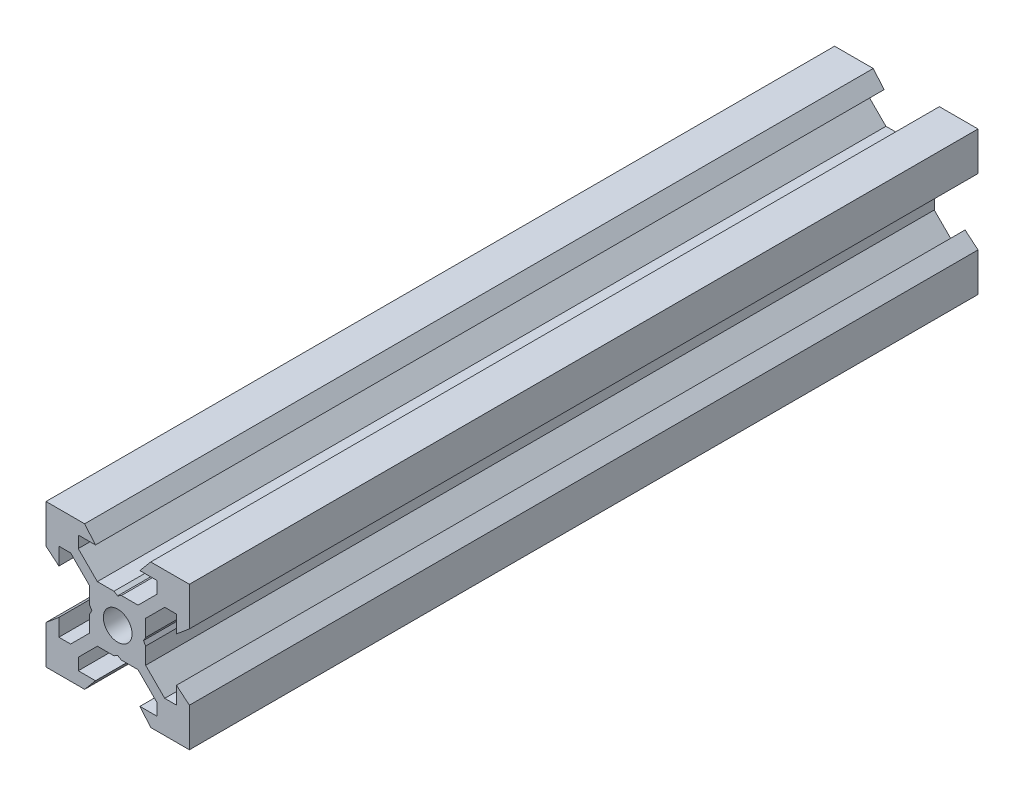
from build123d import *

# Parameters (mm, degrees)
SKETCH1_R           = 2
BOSS_EXTRUDE1_DEPTH = 55


with BuildPart() as part:
    # Sketch1 → Boss-Extrude1 (new body, symmetric)
    with BuildSketch(Plane.XY):
        Polygon((10, 10), (10, 4.610379336), (8.2, 3.1), (8.2, 5.5), (6.560660172, 5.5), (3.9, 2.839339828), (3.9, 0.519615242), (3.6, 0), (3.9, -0.519615242), (3.9, -2.839339828), (6.560660172, -5.5), (8.2, -5.5), (8.2, -3.1), (10, -4.610379336), (10, -10), (4.610379336, -10), (3.1, -8.2), (5.5, -8.2), (5.5, -6.560660172), (2.839339828, -3.9), (0.519615242, -3.9), (0, -3.6), (-0.519615242, -3.9), (-2.839339828, -3.9), (-5.5, -6.560660172), (-5.5, -8.2), (-3.1, -8.2), (-4.610379336, -10), (-10, -10), (-10, -4.610379336), (-8.2, -3.1), (-8.2, -5.5), (-6.560660172, -5.5), (-3.9, -2.839339828), (-3.9, -0.519615242), (-3.6, 0), (-3.9, 0.519615242), (-3.9, 2.839339828), (-6.560660172, 5.5), (-8.2, 5.5), (-8.2, 3.1), (-10, 4.610379336), (-10, 10), (-4.610379336, 10), (-3.1, 8.2), (-5.5, 8.2), (-5.5, 6.560660172), (-2.839339828, 3.9), (-0.519615242, 3.9), (0, 3.6), (0.519615242, 3.9), (2.839339828, 3.9), (5.5, 6.560660172), (5.5, 8.2), (3.1, 8.2), (4.610379336, 10), align=None)
        Circle(SKETCH1_R, mode=Mode.SUBTRACT)
    extrude(amount=BOSS_EXTRUDE1_DEPTH, both=True)


solid = part.part
